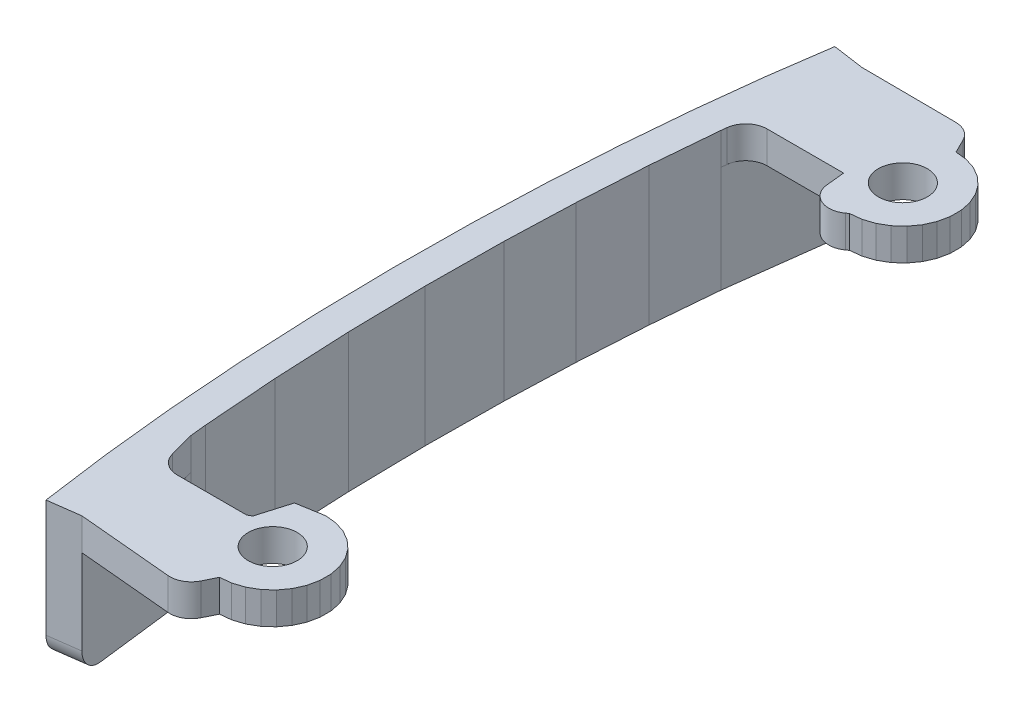
from build123d import *

# Parameters (mm, degrees)
SZKIC2_R                    = 1.15000024
DODANIE_WYCI_GNI_CIE1_DEPTH = 1.5
DODANIE_WYCI_GNI_CIE2_DEPTH = 5
ZAOKR_GLENIE1_R             = 1


with BuildPart() as part:
    # Szkic2 → Dodanie-wyciągnięcie1 (new body)
    with BuildSketch(Plane(origin=(0, 0.9903587, 0), x_dir=(1, 0, 0), z_dir=(0, 1, 0))):
        with BuildLine():
            Line((-173.537057861, -25.629454659), (-177.980234802, -25.600470859))
            Line((-177.980234802, -25.600470859), (-179.465273063, -25.389138502))
            Line((-179.465273063, -25.389138502), (-179.875270484, -28.27020162))
            Line((-179.875270484, -28.27020162), (-180.220882829, -31.315847433))
            Line((-180.220882829, -31.315847433), (-180.496294073, -34.480041019))
            Line((-180.496294073, -34.480041019), (-180.693629515, -37.735565991))
            Line((-180.693629515, -37.735565991), (-180.810996631, -41.053218548))
            Line((-180.810996631, -41.053218548), (-180.844357588, -44.770440674))
            Line((-180.844357588, -44.770440674), (-180.776598606, -48.479996177))
            Line((-180.776598606, -48.479996177), (-180.606637328, -52.137204019))
            Line((-180.606637328, -52.137204019), (-180.340406733, -55.699429047))
            Line((-180.340406733, -55.699429047), (-179.981756968, -59.127877551))
            Line((-179.981756968, -59.127877551), (-179.544751696, -62.365140152))
            Line((-179.544751696, -62.365140152), (-178.058234871, -62.164471942))
            Line((-178.058234871, -62.164471942), (-173.603659928, -62.571167494))
            ThreePointArc((-173.603659928, -62.571167494), (-173.024806006, -62.44819003), (-172.616824171, -62.019533826))
            Line((-172.616824171, -62.019533826), (-172.326234878, -61.433471042))
            Line((-172.326234878, -61.433471042), (-171.806234897, -61.378472644))
            Line((-171.806234897, -61.378472644), (-171.309234799, -61.217471439))
            Line((-171.309234799, -61.217471439), (-170.856234968, -60.956471759))
            Line((-170.856234968, -60.956471759), (-170.468234957, -60.606471377))
            Line((-170.468234957, -60.606471377), (-170.161234797, -60.183471042))
            Line((-170.161234797, -60.183471042), (-169.948234976, -59.706471759))
            Line((-169.948234976, -59.706471759), (-169.840234936, -59.194472629))
            Line((-169.840234936, -59.194472629), (-169.840234936, -58.672471362))
            Line((-169.840234936, -58.672471362), (-169.948234976, -58.160472232))
            Line((-169.948234976, -58.160472232), (-170.161234797, -57.683471042))
            Line((-170.161234797, -57.683471042), (-170.468234957, -57.260472613))
            Line((-170.468234957, -57.260472613), (-170.856234968, -56.910472232))
            Line((-170.856234968, -56.910472232), (-171.309234799, -56.649472552))
            Line((-171.309234799, -56.649472552), (-171.806234897, -56.488471347))
            Line((-171.806234897, -56.488471347), (-172.326234878, -56.433471042))
            Line((-172.326234878, -56.433471042), (-173.590153384, -56.649472552))
            Line((-173.590153384, -56.649472552), (-174.035645958, -58.160472232))
            Line((-174.035645958, -58.160472232), (-174.223992711, -58.263046011))
            Line((-174.223992711, -58.263046011), (-177.48282769, -58.263046011))
            ThreePointArc((-177.48282769, -58.263046011), (-178.091581224, -58.056405409), (-178.448748365, -57.52188428))
            Line((-178.448748365, -57.52188428), (-178.765053408, -56.341511761))
            Line((-178.765053408, -56.341511761), (-178.846234978, -55.565471011))
            Line((-178.846234978, -55.565471011), (-179.109234989, -52.046471912))
            Line((-179.109234989, -52.046471912), (-179.277234734, -48.43147214))
            Line((-179.277234734, -48.43147214), (-179.344234646, -44.763472873))
            Line((-179.344234646, -44.763472873), (-179.311234654, -41.08647092))
            Line((-179.311234654, -41.08647092), (-179.195234955, -37.807471591))
            Line((-179.195234955, -37.807471591), (-179.000234783, -34.590472537))
            Line((-179.000234783, -34.590472537), (-178.728234947, -31.465472537))
            Line((-178.728234947, -31.465472537), (-178.700062197, -31.217205306))
            ThreePointArc((-178.700062197, -31.217205306), (-178.372489594, -30.58405239), (-177.706439248, -30.329959177))
            Line((-177.706439248, -30.329959177), (-174.112522963, -30.329959177))
            Line((-174.112522963, -30.329959177), (-174.022657546, -31.208577866))
            ThreePointArc((-174.022657546, -31.208577866), (-173.436715177, -32.019422034), (-172.441579371, -31.91694544))
            Line((-172.441579371, -31.91694544), (-172.326234878, -31.833472568))
            Line((-172.326234878, -31.833472568), (-171.806234897, -31.778472262))
            Line((-171.806234897, -31.778472262), (-171.309234799, -31.617472964))
            Line((-171.309234799, -31.617472964), (-170.856234968, -31.356471377))
            Line((-170.856234968, -31.356471377), (-170.468234957, -31.006472903))
            Line((-170.468234957, -31.006472903), (-170.161234797, -30.583472568))
            Line((-170.161234797, -30.583472568), (-169.948234976, -30.106471377))
            Line((-169.948234976, -30.106471377), (-169.840234936, -29.59447034))
            Line((-169.840234936, -29.59447034), (-169.840234936, -29.072470981))
            Line((-169.840234936, -29.072470981), (-169.948234976, -28.560469943))
            Line((-169.948234976, -28.560469943), (-170.161234797, -28.083472568))
            Line((-170.161234797, -28.083472568), (-170.468234957, -27.660472232))
            Line((-170.468234957, -27.660472232), (-170.856234968, -27.310469943))
            Line((-170.856234968, -27.310469943), (-171.309234799, -27.049472171))
            Line((-171.309234799, -27.049472171), (-171.806234897, -26.888472873))
            Line((-171.806234897, -26.888472873), (-172.326234878, -26.833472568))
            Line((-172.326234878, -26.833472568), (-172.647665436, -26.185208875))
            ThreePointArc((-172.647665436, -26.185208875), (-173.013661572, -25.781385351), (-173.537057861, -25.629454659))
        make_face()
        with Locations((-172.326039002, -29.333481885)):
            Circle(SZKIC2_R, mode=Mode.SUBTRACT)
        with Locations((-172.326039002, -58.933463325)):
            Circle(SZKIC2_R, mode=Mode.SUBTRACT)
    extrude(amount=DODANIE_WYCI_GNI_CIE1_DEPTH)

    # Szkic3 → Dodanie-wyciągnięcie2 (add)
    with BuildSketch(Plane.XZ.offset(-0.9903587)):
        Polygon((-178.765053408, 56.341511761), (-178.058234871, 62.164471942), (-179.544751696, 62.365140152), (-179.981756968, 59.127877551), (-180.340406733, 55.699429047), (-180.606637328, 52.137204019), (-180.776598606, 48.479996177), (-180.844357588, 44.770440674), (-180.810996631, 41.053218548), (-180.693629515, 37.735565991), (-180.496294073, 34.480041019), (-180.220882829, 31.315847433), (-179.875270484, 28.27020162), (-179.465273063, 25.389138502), (-177.980234802, 25.600470859), (-178.728234947, 31.465472537), (-179.000234783, 34.590472537), (-179.195234955, 37.807471591), (-179.311234654, 41.08647092), (-179.344234646, 44.763472873), (-179.277234734, 48.43147214), (-179.109234989, 52.046471912), (-178.846234978, 55.565471011), align=None)
    extrude(amount=DODANIE_WYCI_GNI_CIE2_DEPTH)

    # Zaokrąglenie1
    zaokr_glenie1_edges = [part.edges().sort_by_distance(p)[0] for p in [
        (-178.722753933, -4.0096413, 25.49480468),
        (-178.801493283, -4.0096413, 62.264806047),
    ]]
    fillet(zaokr_glenie1_edges, radius=ZAOKR_GLENIE1_R)


solid = part.part
